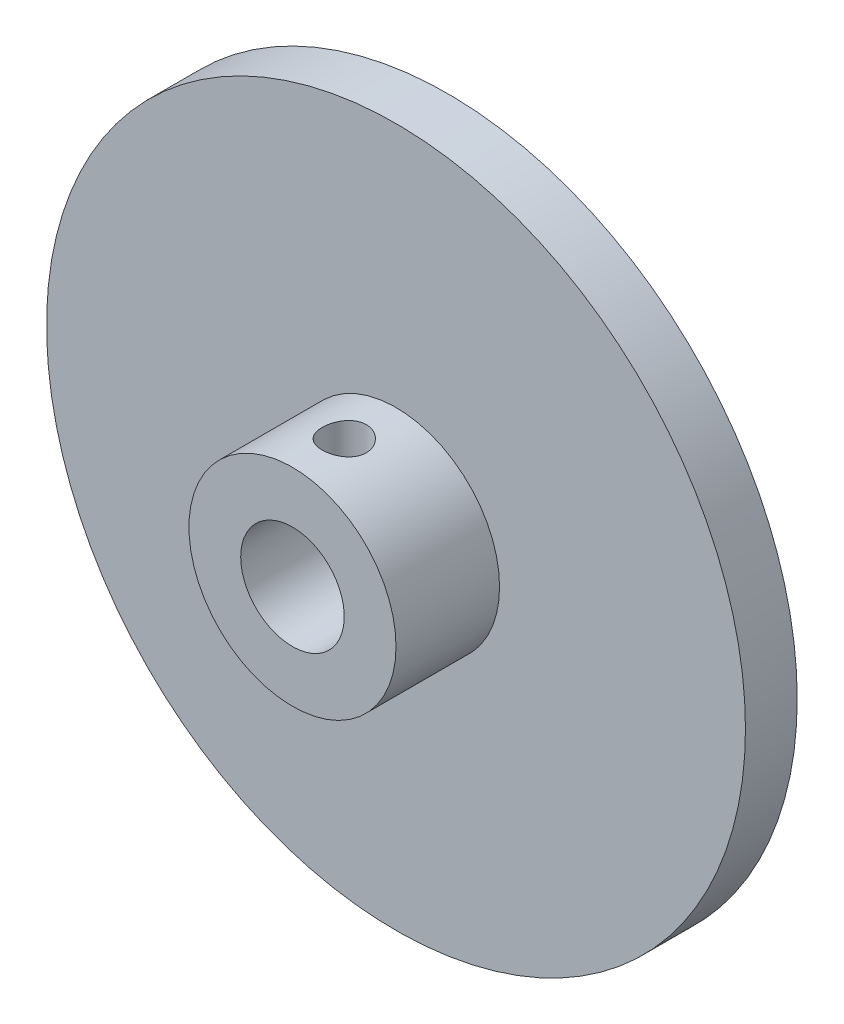
from build123d import *

# Parameters (mm, degrees)
SKETCH1_R                  = 21.43125
BOSS_EXTRUDE1_DEPTH        = 3.175
SKETCH2_R                  = 6.35
BOSS_EXTRUDE2_DEPTH        = 6.35
SKETCH3_R                  = 3.175
CUT_EXTRUDE1_DEPTH         = 32.769837553
F_6_32_TAPPED_HOLE1_REACH  = 38.357
F_6_32_TAPPED_HOLE1_BORE_R = 1.35255


with BuildPart() as part:
    # Sketch1 → Boss-Extrude1 (new body)
    with BuildSketch(Plane.XY):
        Circle(SKETCH1_R)
    extrude(amount=BOSS_EXTRUDE1_DEPTH)

    # Sketch2 → Boss-Extrude2 (add)
    with BuildSketch(Plane.XY.offset(3.175)):
        Circle(SKETCH2_R)
    extrude(amount=BOSS_EXTRUDE2_DEPTH)

    # Sketch3 → Cut-Extrude1 (cut, through all)
    with BuildSketch(Plane(origin=(0, 0, 0), x_dir=(-1, 0, 0), z_dir=(0, 0, -1))):
        Circle(SKETCH3_R)
    extrude(amount=-CUT_EXTRUDE1_DEPTH, mode=Mode.SUBTRACT)

    # #6-32 Tapped Hole1 bore → #6-32 Tapped Hole1 (cut, up to next)
    with BuildSketch(Plane(origin=(0, 6.35, 0), x_dir=(1, 0, 0), z_dir=(0, 1, 0)), mode=Mode.PRIVATE) as f_6_32_tapped_hole1_sk1:
        with Locations((0, -6.35)):
            Circle(F_6_32_TAPPED_HOLE1_BORE_R)
    f_6_32_tapped_hole1_tool1 = extrude(f_6_32_tapped_hole1_sk1.sketch, amount=-F_6_32_TAPPED_HOLE1_REACH, mode=Mode.PRIVATE) & part.part
    add(f_6_32_tapped_hole1_tool1.solids().sort_by_distance((0, 6.35, 6.35))[0], mode=Mode.SUBTRACT)


solid = part.part
